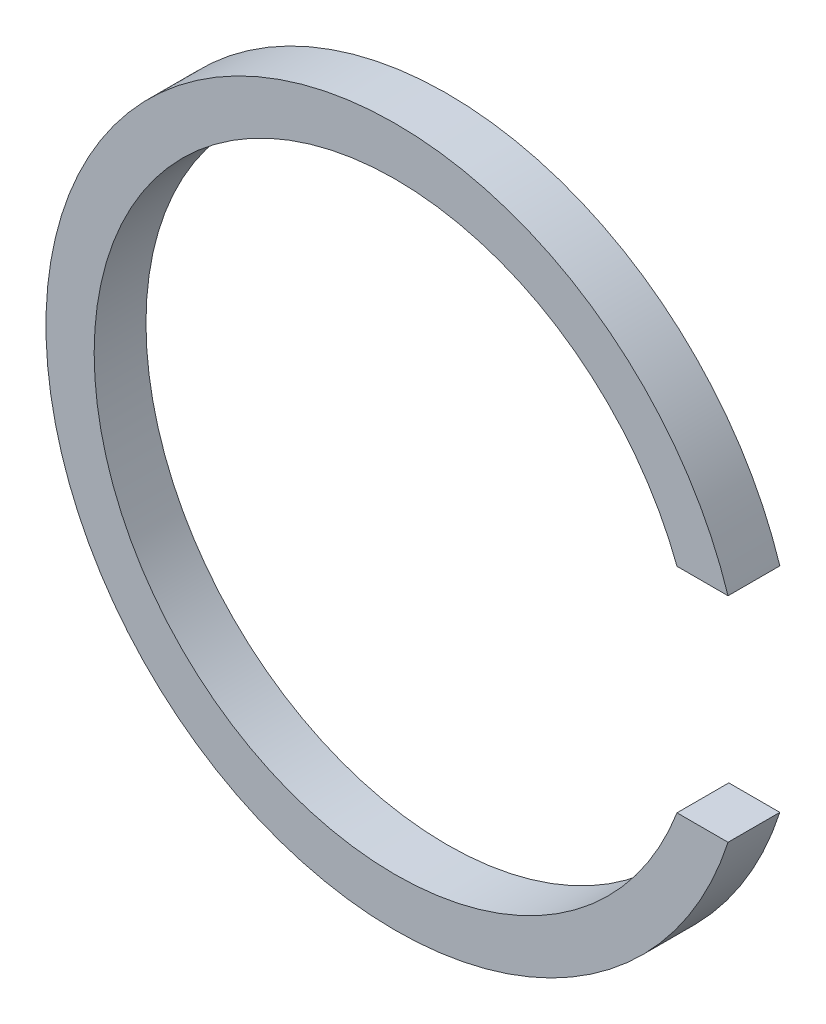
from build123d import *

# Parameters (mm, degrees)
BOSS_EXTRUDE1_DEPTH = 12.9


with BuildPart() as part:
    # Sketch1 → Boss-Extrude1 (new body)
    with BuildSketch(Plane.XY):
        with BuildLine():
            Line((70.133938824, 26.575), (82.841833484, 26.575))
            ThreePointArc((82.841833484, 26.575), (-87, 0), (82.841833484, -26.575))
            Line((82.841833484, -26.575), (70.133938824, -26.575))
            ThreePointArc((70.133938824, -26.575), (-75, 0), (70.133938824, 26.575))
        make_face()
    extrude(amount=BOSS_EXTRUDE1_DEPTH)


solid = part.part
